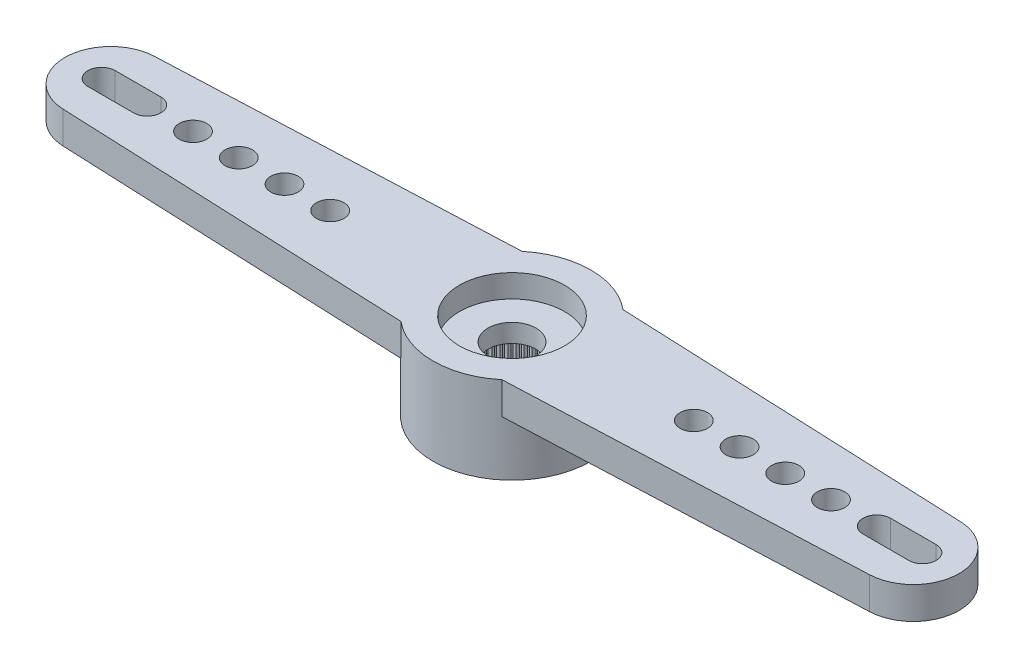
from build123d import *

# Parameters (mm, degrees)
RESSALTO_EXTRUS_O1_DEPTH = 1.4
ESBO_O2_R                = 3.45
RESSALTO_EXTRUS_O2_DEPTH = 2.4
FURO4_D                  = 1.2
PADR_O_LINEAR1_COUNT     = 6
PADR_O_LINEAR1_PITCH     = 2
PADR_OCIRCULAR2_COUNT    = 2
PADR_OCIRCULAR2_COPY_1_D = 1.2
PADR_OCIRCULAR2_COPY_2_D = 1.2
PADR_OCIRCULAR2_COPY_3_D = 1.2
PADR_OCIRCULAR2_COPY_4_D = 1.2
PADR_OCIRCULAR2_COPY_5_D = 1.2
FURO1_D                  = 4.95
FURO1_DEPTH              = 2
FURO2_D                  = 4.6
FURO2_DEPTH              = 1
FURO3_D                  = 2.1
RESSALTO_EXTRUS_O3_DEPTH = 2
PADR_OCIRCULAR1_COUNT    = 60
SKETCH1_W                = 2
SKETCH1_H                = 1.2
CUT_EXTRUDE1_DEPTH       = 1
CUT_EXTRUDE1_DEPTH_BACK  = 4.8


with BuildPart() as part:
    # Esboço1 → Ressalto-extrusão1 (new body)
    with BuildSketch(Plane(origin=(0, 0, 0), x_dir=(1, 0, 0), z_dir=(0, 1, 0))):
        with BuildLine():
            Line((-17.634432639, 1.998216988), (-2.209072203, 2.65))
            ThreePointArc((-2.209072203, 2.65), (3.45, 0), (-2.209072203, -2.65))
            Line((-2.209072203, -2.65), (-17.634432639, -1.998216988))
            ThreePointArc((-17.634432639, -1.998216988), (-19.55, 0), (-17.634432639, 1.998216988))
        make_face()
    ressalto_extrus_o1 = extrude(amount=-RESSALTO_EXTRUS_O1_DEPTH)

    # Esboço2 → Ressalto-extrusão2 (add)
    with BuildSketch(Plane.XZ.offset(1.4)):
        Circle(ESBO_O2_R)
    extrude(amount=RESSALTO_EXTRUS_O2_DEPTH)

    # Furo4 (through all)
    with Locations(Plane(origin=(0, 0, 0), x_dir=(1, 0, 0), z_dir=(0, 1, 0))):
        with Locations((-17.95, 0)):
            furo4 = Hole(FURO4_D / 2)

    # Padrão linear1: Furo4 ×6
    with Locations(*[(i * PADR_O_LINEAR1_PITCH, 0, 0) for i in range(1, PADR_O_LINEAR1_COUNT)]):
        add(furo4, mode=Mode.SUBTRACT)

    # PadrãoCircular2: Ressalto-extrusão1, Furo4 ×2 about axis
    padr_ocircular2_axis = Axis((0, 0, 0), (0, 1, 0))
    for i in range(1, PADR_OCIRCULAR2_COUNT):
        add(ressalto_extrus_o1.rotate(padr_ocircular2_axis, i * 360 / PADR_OCIRCULAR2_COUNT))
        add(furo4.rotate(padr_ocircular2_axis, i * 360 / PADR_OCIRCULAR2_COUNT), mode=Mode.SUBTRACT)

    # PadrãoCircular2 copy 1 (through all)
    with Locations(Plane(origin=(-2, 0, 0), x_dir=(-1, 0, 0), z_dir=(0, 1, 0))):
        with Locations((-17.95, 0)):
            Hole(PADR_OCIRCULAR2_COPY_1_D / 2)

    # PadrãoCircular2 copy 2 (through all)
    with Locations(Plane(origin=(-4, 0, 0), x_dir=(-1, 0, 0), z_dir=(0, 1, 0))):
        with Locations((-17.95, 0)):
            Hole(PADR_OCIRCULAR2_COPY_2_D / 2)

    # PadrãoCircular2 copy 3 (through all)
    with Locations(Plane(origin=(-6, 0, 0), x_dir=(-1, 0, 0), z_dir=(0, 1, 0))):
        with Locations((-17.95, 0)):
            Hole(PADR_OCIRCULAR2_COPY_3_D / 2)

    # PadrãoCircular2 copy 4 (through all)
    with Locations(Plane(origin=(-8, 0, 0), x_dir=(-1, 0, 0), z_dir=(0, 1, 0))):
        with Locations((-17.95, 0)):
            Hole(PADR_OCIRCULAR2_COPY_4_D / 2)

    # PadrãoCircular2 copy 5 (through all)
    with Locations(Plane(origin=(-10, 0, 0), x_dir=(-1, 0, 0), z_dir=(0, 1, 0))):
        with Locations((-17.95, 0)):
            Hole(PADR_OCIRCULAR2_COPY_5_D / 2)

    # Furo1
    with Locations(Plane(origin=(0, -3.8, 0), x_dir=(-1, 0, 0), z_dir=(0, -1, 0))):
        with Locations((0, 0)):
            Hole(FURO1_D / 2, depth=FURO1_DEPTH)

    # Furo2
    with Locations(Plane(origin=(0, 0, 0), x_dir=(1, 0, 0), z_dir=(0, 1, 0))):
        with Locations((0, 0)):
            Hole(FURO2_D / 2, depth=FURO2_DEPTH)

    # Furo3 (through all)
    with Locations(Plane(origin=(0, 0, 0), x_dir=(1, 0, 0), z_dir=(0, 1, 0))):
        with Locations((0, 0)):
            Hole(FURO3_D / 2)

    # Esboço11 → Ressalto-extrusão3 (add)
    with BuildSketch(Plane.XZ.offset(3.8)):
        with BuildLine():
            Line((-0.098056786, 2.473056786), (0, 2.375))
            Line((0, 2.375), (0.098056786, 2.473056786))
            ThreePointArc((0.098056786, 2.473056786), (0, 2.475), (-0.098056786, 2.473056786))
        make_face()
    ressalto_extrus_o3 = extrude(amount=-RESSALTO_EXTRUS_O3_DEPTH)

    # PadrãoCircular1: Ressalto-extrusão3 ×60 about axis
    padr_ocircular1_axis = Axis((0, 0, 0), (0, 1, 0))
    for i in range(1, PADR_OCIRCULAR1_COUNT):
        add(ressalto_extrus_o3.rotate(padr_ocircular1_axis, i * 360 / PADR_OCIRCULAR1_COUNT))

    # Sketch1 → Cut-Extrude1 (cut, two sides)
    with BuildSketch(Plane(origin=(0, 0, 0), x_dir=(1, 0, 0), z_dir=(0, 1, 0))) as cut_extrude1_sk:
        with Locations((-16.95, 0)):
            Rectangle(SKETCH1_W, SKETCH1_H)
        with Locations((16.95, 0)):
            Rectangle(SKETCH1_W, SKETCH1_H)
    extrude(amount=CUT_EXTRUDE1_DEPTH, mode=Mode.SUBTRACT)
    extrude(cut_extrude1_sk.sketch, amount=-CUT_EXTRUDE1_DEPTH_BACK, mode=Mode.SUBTRACT)


solid = part.part
